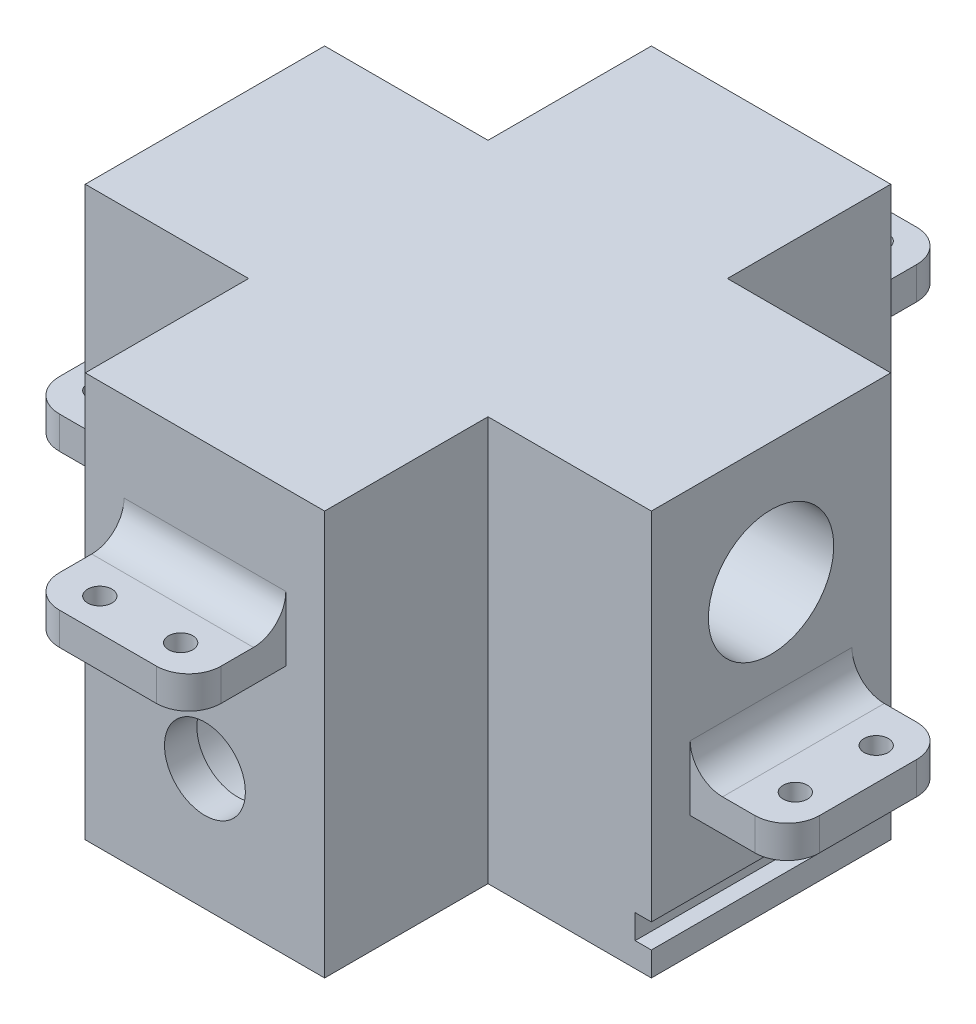
from build123d import *

# Parameters (mm, degrees)
ESQUISSE1_W              = 70
ESQUISSE1_H              = 50
BOSS_EXTRU_1_DEPTH       = 70
ESQUISSE2_R              = 7.75
ENL_V_MAT_EXTRU_1_DEPTH  = 71
ESQUISSE3_R              = 7.75
ENL_V_MAT_EXTRU_2_DEPTH  = 71
ESQUISSE4_W              = 20.2
ESQUISSE4_H              = 20.2
ENL_V_MAT_EXTRU_3_DEPTH  = 51
ESQUISSE7_R              = 11.73674641
ESQUISSE7_R_2            = 5
BOSS_EXTRU_3_DEPTH       = 4
ESQUISSE8_R              = 12.196693844
ESQUISSE8_R_2            = 5
BOSS_EXTRU_4_DEPTH       = 4
ESQUISSE9_W              = 2
ESQUISSE9_H              = 3
ENL_V_MAT_EXTRU_4_DEPTH  = 50.8
ESQUISSE10_W             = 2
ESQUISSE10_H             = 3
ENL_V_MAT_EXTRU_5_DEPTH  = 50.8
ESQUISSE11_W             = 2
ESQUISSE11_H             = 3
ENL_V_MAT_EXTRU_6_DEPTH  = 50.8
ESQUISSE12_W             = 20
ESQUISSE12_H             = 4
BOSS_EXTRU_5_DEPTH       = 12
ESQUISSE13_R             = 1.5
ENL_V_MAT_EXTRU_7_DEPTH  = 36
CONG_1_R                 = 4
ESQUISSE14_W             = 20
ESQUISSE14_H             = 4
BOSS_EXTRU_6_DEPTH       = 12
ESQUISSE15_R             = 1.5
ENL_V_MAT_EXTRU_8_DEPTH  = 36
CONG_3_R                 = 4
ESQUISSE16_W             = 20
ESQUISSE16_H             = 4
BOSS_EXTRU_7_DEPTH       = 12
ESQUISSE17_R             = 1.5
ENL_V_MAT_EXTRU_9_DEPTH  = 20
CONG_4_R                 = 4
ESQUISSE18_W             = 20
ESQUISSE18_H             = 4
BOSS_EXTRU_8_DEPTH       = 12
ESQUISSE19_R             = 1.5
ENL_V_MAT_EXTRU_10_DEPTH = 20
CONG_5_R                 = 4
CONG_6_R                 = 4


with BuildPart() as part:
    # Esquisse1 → Boss.-Extru.1 (new body)
    with BuildSketch(Plane(origin=(0, 0, 0), x_dir=(0, 0, -1), z_dir=(1, 0, 0))):
        with Locations((35, 25)):
            Rectangle(ESQUISSE1_W, ESQUISSE1_H)
    extrude(amount=BOSS_EXTRU_1_DEPTH)

    # Esquisse2 → Enlèv. mat.-Extru.1 (cut, through all)
    with BuildSketch(Plane.XY):
        with Locations((35, 15)):
            Circle(ESQUISSE2_R)
    extrude(amount=-ENL_V_MAT_EXTRU_1_DEPTH, mode=Mode.SUBTRACT)

    # Esquisse3 → Enlèv. mat.-Extru.2 (cut, through all)
    with BuildSketch(Plane.ZY):
        with Locations((-35, 35)):
            Circle(ESQUISSE3_R)
    extrude(amount=-ENL_V_MAT_EXTRU_2_DEPTH, mode=Mode.SUBTRACT)

    # Esquisse4 → Enlèv. mat.-Extru.3 (cut, through all)
    with BuildSketch(Plane.XZ):
        with Locations((10.1, -59.9)):
            Rectangle(ESQUISSE4_W, ESQUISSE4_H)
        with Locations((10.1, -10.1)):
            Rectangle(ESQUISSE4_W, ESQUISSE4_H)
        with Locations((59.9, -10.1)):
            Rectangle(ESQUISSE4_W, ESQUISSE4_H)
        with Locations((59.9, -59.9)):
            Rectangle(ESQUISSE4_W, ESQUISSE4_H)
    extrude(amount=-ENL_V_MAT_EXTRU_3_DEPTH, mode=Mode.SUBTRACT)

    # Esquisse7 → Boss.-Extru.3 (add)
    with BuildSketch(Plane.XY):
        with Locations((35, 15)):
            Circle(ESQUISSE7_R)
        with Locations((35, 15)):
            Circle(ESQUISSE7_R_2, mode=Mode.SUBTRACT)
    extrude(amount=-BOSS_EXTRU_3_DEPTH)

    # Esquisse8 → Boss.-Extru.4 (add)
    with BuildSketch(Plane.ZY):
        with Locations((-35, 35)):
            Circle(ESQUISSE8_R)
        with Locations((-35, 35)):
            Circle(ESQUISSE8_R_2, mode=Mode.SUBTRACT)
    extrude(amount=-BOSS_EXTRU_4_DEPTH)

    # Esquisse9 → Enlèv. mat.-Extru.4 (cut, through all)
    with BuildSketch(Plane.ZY.offset(-20.2)):
        with Locations((-69, 4.5)):
            Rectangle(ESQUISSE9_W, ESQUISSE9_H)
    extrude(amount=-ENL_V_MAT_EXTRU_4_DEPTH, mode=Mode.SUBTRACT)

    # Esquisse10 → Enlèv. mat.-Extru.5 (cut, through all)
    with BuildSketch(Plane(origin=(0, 0, -49.8), x_dir=(-1, 0, 0), z_dir=(0, 0, -1))):
        with Locations((-1, 4.5)):
            Rectangle(ESQUISSE10_W, ESQUISSE10_H)
    extrude(amount=-ENL_V_MAT_EXTRU_5_DEPTH, mode=Mode.SUBTRACT)

    # Esquisse11 → Enlèv. mat.-Extru.6 (cut, through all)
    with BuildSketch(Plane(origin=(0, 0, -49.8), x_dir=(-1, 0, 0), z_dir=(0, 0, -1))):
        with Locations((-69, 4.5)):
            Rectangle(ESQUISSE11_W, ESQUISSE11_H)
    extrude(amount=-ENL_V_MAT_EXTRU_6_DEPTH, mode=Mode.SUBTRACT)

    # Esquisse12 → Boss.-Extru.5 (add)
    with BuildSketch(Plane.ZY):
        with Locations((-35, 17)):
            Rectangle(ESQUISSE12_W, ESQUISSE12_H)
    extrude(amount=BOSS_EXTRU_5_DEPTH)

    # Esquisse13 → Enlèv. mat.-Extru.7 (cut, through all)
    with BuildSketch(Plane.XZ.offset(-15)):
        with Locations(Location((-8, -30, 0), (0, 0, 270))):  # turned: the seam where the file's is
            Circle(ESQUISSE13_R)
        with Locations(Location((-8, -40, 0), (0, 0, 270))):  # turned: the seam where the file's is
            Circle(ESQUISSE13_R)
    extrude(amount=-ENL_V_MAT_EXTRU_7_DEPTH, mode=Mode.SUBTRACT)

    # Congé1
    cong_1_edges = [part.edges().sort_by_distance(p)[0] for p in [
        (-12, 17, -25),
        (-12, 17, -45),
    ]]
    fillet(cong_1_edges, radius=CONG_1_R)

    # Esquisse14 → Boss.-Extru.6 (add)
    with BuildSketch(Plane(origin=(70, 0, 0), x_dir=(0, 0, -1), z_dir=(1, 0, 0))):
        with Locations((35, 17)):
            Rectangle(ESQUISSE14_W, ESQUISSE14_H)
    extrude(amount=BOSS_EXTRU_6_DEPTH)

    # Esquisse15 → Enlèv. mat.-Extru.8 (cut, through all)
    with BuildSketch(Plane.XZ.offset(-15)):
        with Locations(Location((78, -40, 0), (0, 0, 270))):  # turned: the seam where the file's is
            Circle(ESQUISSE15_R)
        with Locations(Location((78, -30, 0), (0, 0, 270))):  # turned: the seam where the file's is
            Circle(ESQUISSE15_R)
    extrude(amount=-ENL_V_MAT_EXTRU_8_DEPTH, mode=Mode.SUBTRACT)

    # Congé3
    cong_3_edges = [part.edges().sort_by_distance(p)[0] for p in [
        (82, 17, -45),
        (82, 17, -25),
    ]]
    fillet(cong_3_edges, radius=CONG_3_R)

    # Esquisse16 → Boss.-Extru.7 (add)
    with BuildSketch(Plane.XY):
        with Locations((35, 33)):
            Rectangle(ESQUISSE16_W, ESQUISSE16_H)
    extrude(amount=BOSS_EXTRU_7_DEPTH)

    # Esquisse17 → Enlèv. mat.-Extru.9 (cut, through all)
    with BuildSketch(Plane.XZ.offset(-31)):
        with Locations((40, 8)):
            Circle(ESQUISSE17_R)
        with Locations((30, 8)):
            Circle(ESQUISSE17_R)
    extrude(amount=-ENL_V_MAT_EXTRU_9_DEPTH, mode=Mode.SUBTRACT)

    # Congé4
    cong_4_edges = [part.edges().sort_by_distance(p)[0] for p in [
        (45, 33, 12),
        (25, 33, 12),
    ]]
    fillet(cong_4_edges, radius=CONG_4_R)

    # Esquisse18 → Boss.-Extru.8 (add)
    with BuildSketch(Plane(origin=(0, 0, -70), x_dir=(-1, 0, 0), z_dir=(0, 0, -1))):
        with Locations((-35, 33)):
            Rectangle(ESQUISSE18_W, ESQUISSE18_H)
    extrude(amount=BOSS_EXTRU_8_DEPTH)

    # Esquisse19 → Enlèv. mat.-Extru.10 (cut, through all)
    with BuildSketch(Plane.XZ.offset(-31)):
        with Locations((30, -78)):
            Circle(ESQUISSE19_R)
        with Locations((40, -78)):
            Circle(ESQUISSE19_R)
    extrude(amount=-ENL_V_MAT_EXTRU_10_DEPTH, mode=Mode.SUBTRACT)

    # Congé5
    cong_5_edges = [part.edges().sort_by_distance(p)[0] for p in [
        (25, 33, -82),
        (45, 33, -82),
    ]]
    fillet(cong_5_edges, radius=CONG_5_R)

    # Congé6
    cong_6_edges = [part.edges().sort_by_distance(p)[0] for p in [
        (0, 19, -35),
        (70, 19, -35),
        (35, 35, 0),
        (35, 35, -70),
    ]]
    fillet(cong_6_edges, radius=CONG_6_R)


solid = part.part
